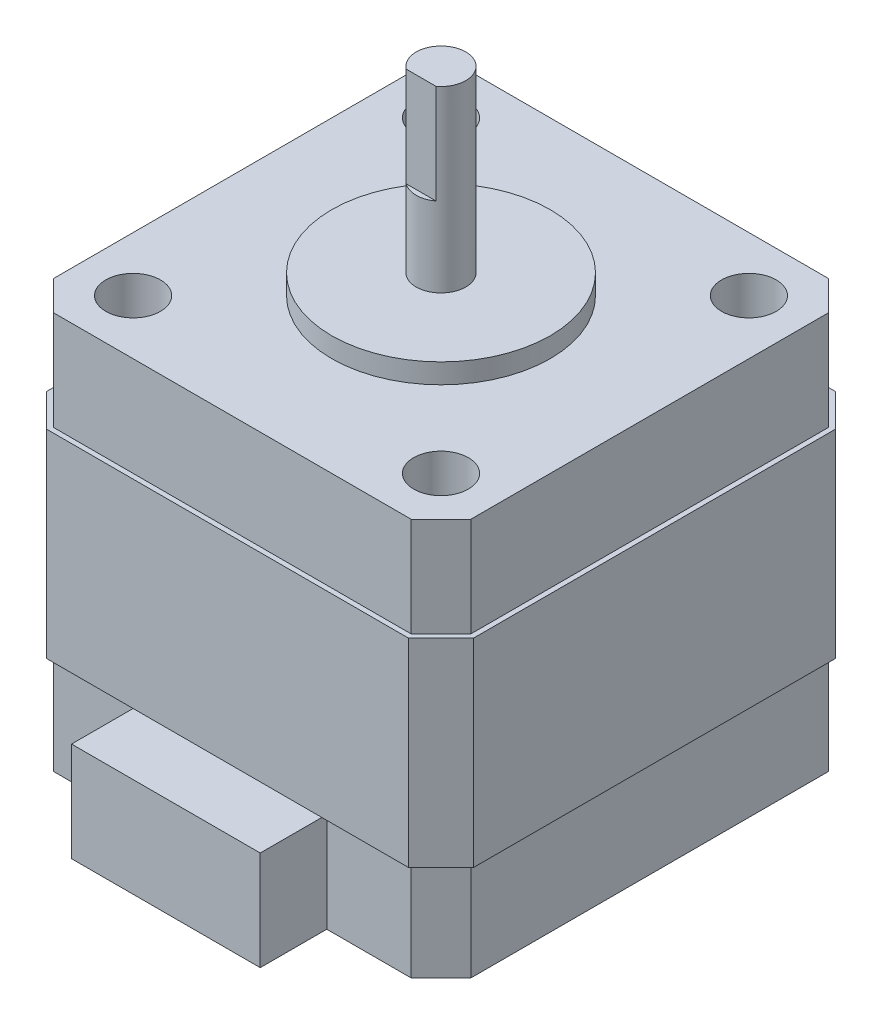
from build123d import *

# Parameters (mm, degrees)
EXTRUDE_1_DEPTH              = 10
EXTRUDE_3_DEPTH              = 20
EXTRUDE_4_DEPTH              = 10
SKETCH_4_R                   = 11
EXTRUDE_5_DEPTH              = 2
SKETCH_5_R                   = 2.5
EXTRUDE_6_DEPTH              = 18
SKETCH_6_W                   = 19
SKETCH_6_H                   = 10
EXTRUDE_7_DEPTH              = 6.7
CUT_EXTRUDE_1_DEPTH          = 10
HOLE_WIZARD_M3_1_D           = 2.5
HOLE_WIZARD_M3_1_DEPTH       = 14
HOLE_WIZARD_M3_1_CBORE_D     = 5.5
HOLE_WIZARD_M3_1_CBORE_DEPTH = 4.5
HOLE_WIZARD_M3_1_TIP         = 0.751075774


with BuildPart() as part:
    # 草图1 → 凸台-拉伸1 (new body)
    with BuildSketch(Plane(origin=(0, 0, 0), x_dir=(1, 0, 0), z_dir=(0, 1, 0))):
        Polygon((-21, 18), (-18, 21), (18, 21), (21, 18), (21, -18), (18, -21), (-18, -21), (-21, -18), align=None)
    extrude(amount=EXTRUDE_1_DEPTH)

    # 草图2 → 凸台-拉伸3 (add)
    with BuildSketch(Plane(origin=(0, 10, 0), x_dir=(1, 0, 0), z_dir=(0, 1, 0))):
        Polygon((21.5, 18.207106781), (18.207106781, 21.5), (-18.207106781, 21.5), (-21.5, 18.207106781), (-21.5, -18.207106781), (-18.207106781, -21.5), (18.207106781, -21.5), (21.5, -18.207106781), align=None)
    extrude(amount=EXTRUDE_3_DEPTH)

    # 草图3 → 凸台-拉伸4 (add)
    with BuildSketch(Plane(origin=(0, 30, 0), x_dir=(1, 0, 0), z_dir=(0, 1, 0))):
        Polygon((21, -18), (21, 18), (18, 21), (-18, 21), (-21, 18), (-21, -18), (-18, -21), (18, -21), align=None)
    extrude(amount=EXTRUDE_4_DEPTH)

    # 草图4 → 凸台-拉伸5 (add)
    with BuildSketch(Plane(origin=(0, 40, 0), x_dir=(1, 0, 0), z_dir=(0, 1, 0))):
        Circle(SKETCH_4_R)
    extrude(amount=EXTRUDE_5_DEPTH)

    # 草图5 → 凸台-拉伸6 (add)
    with BuildSketch(Plane(origin=(0, 42, 0), x_dir=(1, 0, 0), z_dir=(0, 1, 0))):
        Circle(SKETCH_5_R)
    extrude(amount=EXTRUDE_6_DEPTH)

    # 草图6 → 凸台-拉伸7 (add)
    with BuildSketch(Plane.XY.offset(21)):
        with Locations((0, 5)):
            Rectangle(SKETCH_6_W, SKETCH_6_H)
    extrude(amount=EXTRUDE_7_DEPTH)

    # 草图7 → 切除-拉伸1 (cut)
    with BuildSketch(Plane(origin=(0, 60, 0), x_dir=(1, 0, 0), z_dir=(0, 1, 0))):
        with BuildLine():
            Line((-1.5, -2), (1.5, -2))
            ThreePointArc((1.5, -2), (0, -2.5), (-1.5, -2))
        make_face()
    extrude(amount=-CUT_EXTRUDE_1_DEPTH, mode=Mode.SUBTRACT)

    # M3 六角头机械螺钉的柱形沉头孔1
    with Locations(Plane(origin=(0, 40, 0), x_dir=(1, 0, 0), z_dir=(0, 1, 0))):
        with Locations((-15.5, 15.5), (15.5, 15.5), (-15.5, -15.5), (15.5, -15.5)):
            CounterBoreHole(HOLE_WIZARD_M3_1_D / 2, HOLE_WIZARD_M3_1_CBORE_D / 2, HOLE_WIZARD_M3_1_CBORE_DEPTH, depth=HOLE_WIZARD_M3_1_DEPTH)
            with Locations((0, 0, -(HOLE_WIZARD_M3_1_DEPTH + HOLE_WIZARD_M3_1_TIP / 2))):  # 118° drill point
                Cone(0, HOLE_WIZARD_M3_1_D / 2, HOLE_WIZARD_M3_1_TIP, mode=Mode.SUBTRACT)


solid = part.part
